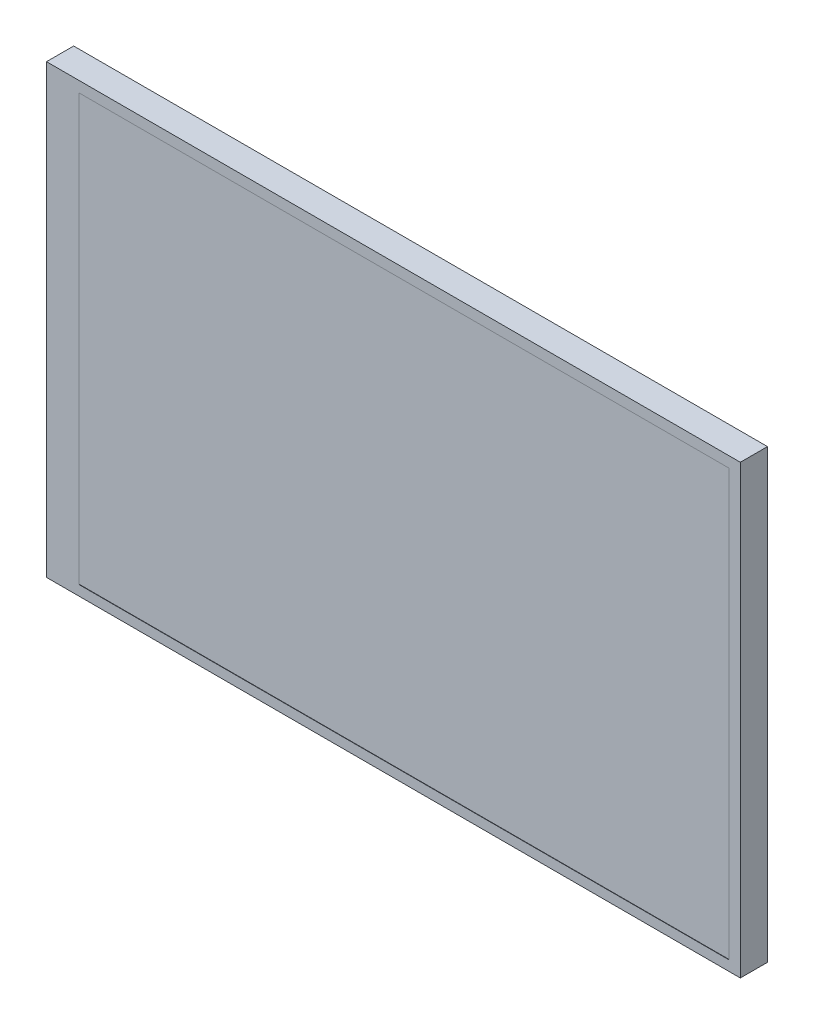
from build123d import *

# Parameters (mm, degrees)
ESQUISSE1_W             = 94.57
ESQUISSE1_H             = 60.88
BOSS_EXTRU_1_DEPTH      = 3.7
ESQUISSE2_W             = 88.629386258
ESQUISSE2_H             = 58.041323691
ENL_V_MAT_EXTRU_1_DEPTH = 0.05
ESQUISSE3_W             = 3.887425577
ESQUISSE3_H             = 19.495847756
BOSS_EXTRU_2_DEPTH      = 0.05
ESQUISSE4_W             = 3.887425577
ESQUISSE4_H             = 19.495847756
BOSS_EXTRU_3_DEPTH      = 0.1


with BuildPart() as part:
    # Esquisse1 → Boss.-Extru.1 (new body)
    with BuildSketch(Plane.XY):
        with Locations((47.285, 30.44)):
            Rectangle(ESQUISSE1_W, ESQUISSE1_H)
    extrude(amount=BOSS_EXTRU_1_DEPTH)

    # Esquisse2 → Enlèv. mat.-Extru.1 (cut)
    with BuildSketch(Plane.XY.offset(3.7)):
        with Locations((48.709909747, 30.392503009)):
            Rectangle(ESQUISSE2_W, ESQUISSE2_H)
    extrude(amount=-ENL_V_MAT_EXTRU_1_DEPTH, mode=Mode.SUBTRACT)

    # Esquisse3 → Boss.-Extru.2 (add)
    with BuildSketch(Plane(origin=(0, 0, 0), x_dir=(-1, 0, 0), z_dir=(0, 0, -1))):
        with BuildLine():
            Line((-9.099589702, 9.441066071), (0, 9.441066071))
            Line((0, 9.441066071), (0, 51.438933929))
            Line((0, 51.438933929), (-9.099589702, 51.438933929))
            ThreePointArc((-9.099589702, 51.438933929), (-10.513803264, 50.853147491), (-11.099589702, 49.438933929))
            Line((-11.099589702, 49.438933929), (-11.099589702, 42.94))
            ThreePointArc((-11.099589702, 42.94), (-11.68537614, 41.525786438), (-13.099589702, 40.94))
            Line((-13.099589702, 40.94), (-40, 40.94))
            Line((-40, 40.94), (-40, 19.94))
            Line((-40, 19.94), (-13.099589702, 19.94))
            ThreePointArc((-13.099589702, 19.94), (-11.68537614, 19.354213562), (-11.099589702, 17.94))
            Line((-11.099589702, 17.94), (-11.099589702, 11.441066071))
            ThreePointArc((-11.099589702, 11.441066071), (-10.513803264, 10.026852509), (-9.099589702, 9.441066071))
        make_face()
        with Locations((-37.941401464, 30.44)):
            Rectangle(ESQUISSE3_W, ESQUISSE3_H, mode=Mode.SUBTRACT)
    extrude(amount=BOSS_EXTRU_2_DEPTH)

    # Esquisse4 → Boss.-Extru.3 (add)
    with BuildSketch(Plane(origin=(0, 0, 0), x_dir=(-1, 0, 0), z_dir=(0, 0, -1))):
        with Locations((-37.941401464, 30.44)):
            Rectangle(ESQUISSE4_W, ESQUISSE4_H)
    extrude(amount=BOSS_EXTRU_3_DEPTH)


solid = part.part
